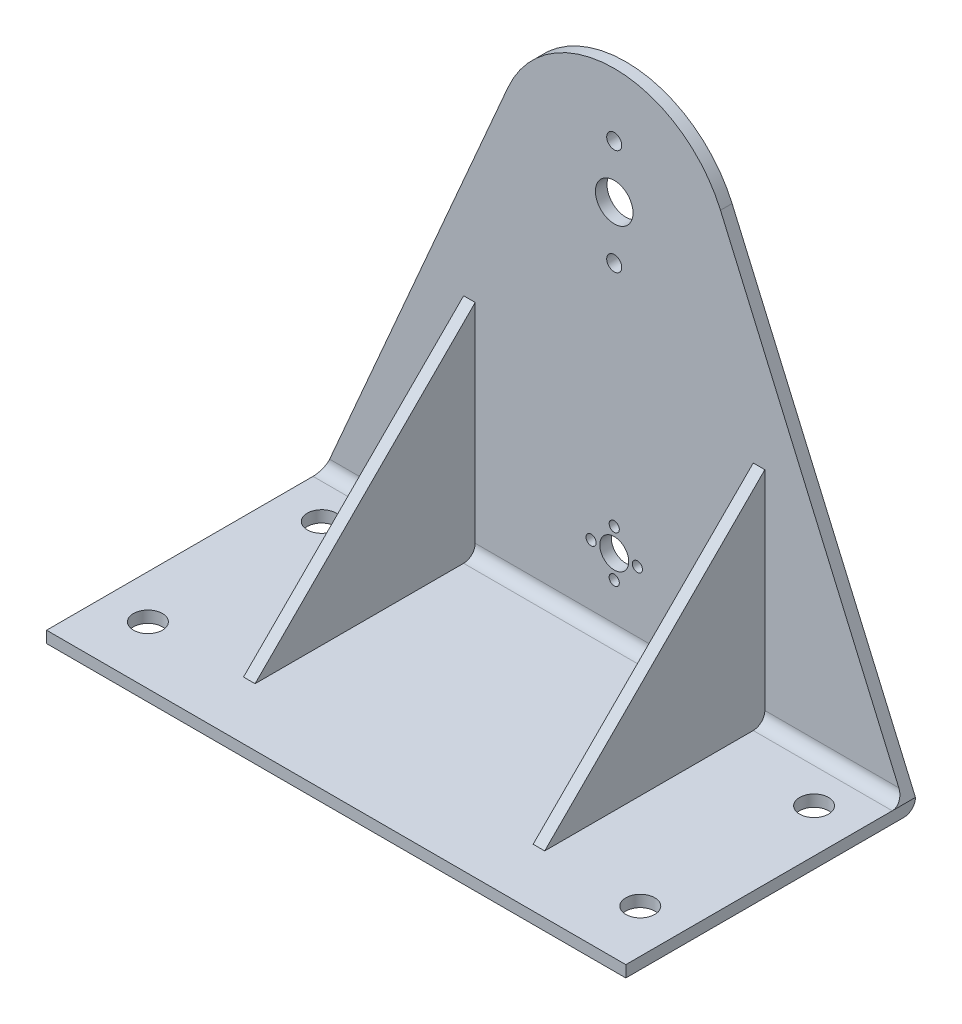
from build123d import *

# Parameters (mm, degrees)
SKETCH1_R           = 6.5
BOSS_EXTRUDE1_DEPTH = 4
SKETCH4_R           = 2.6
CUT_EXTRUDE1_DEPTH  = 10
SKETCH5_W           = 200
SKETCH5_H           = 4
BOSS_EXTRUDE2_DEPTH = 100
FILLET1_R           = 4
SKETCH8_R           = 5
CUT_EXTRUDE2_DEPTH  = 100
SKETCH9_R           = 5
SKETCH9_R_2         = 1.75
CUT_EXTRUDE3_DEPTH  = 10
RIB1_REACH          = 249.79
SKETCH10_WALL_W     = 610.717552724
SKETCH10_WALL_H     = 4


with BuildPart() as part:
    # Sketch1 → Boss-Extrude1 (new body)
    with BuildSketch(Plane.XY):
        with BuildLine():
            Line((100, -4), (100, 0))
            Line((100, 0), (36.695562583, 145.919663525))
            ThreePointArc((36.695562583, 145.919663525), (0, 170), (-36.695562583, 145.919663525))
            Line((-36.695562583, 145.919663525), (-100, 0))
            Line((-100, 0), (-100, -4))
            Line((-100, -4), (100, -4))
        make_face()
        with Locations((0, 130)):
            Circle(SKETCH1_R, mode=Mode.SUBTRACT)
    extrude(amount=BOSS_EXTRUDE1_DEPTH)

    # Sketch4 → Cut-Extrude1 (cut)
    with BuildSketch(Plane(origin=(0, 0, 0), x_dir=(-1, 0, 0), z_dir=(0, 0, -1))):
        with Locations((0, 111.75)):
            Circle(SKETCH4_R)
        with Locations((0, 148.25)):
            Circle(SKETCH4_R)
    extrude(amount=-CUT_EXTRUDE1_DEPTH, mode=Mode.SUBTRACT)

    # Sketch5 → Boss-Extrude2 (add)
    with BuildSketch(Plane(origin=(0, 0, 0), x_dir=(-1, 0, 0), z_dir=(0, 0, -1))):
        with Locations((0, -2)):
            Rectangle(SKETCH5_W, SKETCH5_H)
    extrude(amount=-BOSS_EXTRUDE2_DEPTH)

    # Fillet1
    fillet1_edges = [part.edges().sort_by_distance(p)[0] for p in [
        (0, -4, 0),
        (0, 0, 4),
    ]]
    fillet(fillet1_edges, radius=FILLET1_R)

    # Sketch8 → Cut-Extrude2 (cut)
    with BuildSketch(Plane(origin=(0, 0, 0), x_dir=(1, 0, 0), z_dir=(0, 1, 0))):
        with Locations(Location((-85, -80, 0), (0, 0, 270))):
            Circle(SKETCH8_R)
        with Locations(Location((-85, -20, 0), (0, 0, 270))):
            Circle(SKETCH8_R)
        with Locations(Location((85, -80, 0), (0, 0, 270))):
            Circle(SKETCH8_R)
        with Locations(Location((85, -20, 0), (0, 0, 270))):
            Circle(SKETCH8_R)
    extrude(amount=-CUT_EXTRUDE2_DEPTH, mode=Mode.SUBTRACT)

    # Sketch9 → Cut-Extrude3 (cut)
    with BuildSketch(Plane.XY.offset(4)):
        with Locations((0, 25)):
            Circle(SKETCH9_R)
        with Locations((0, 33)):
            Circle(SKETCH9_R_2)
        with Locations((0, 17)):
            Circle(SKETCH9_R_2)
        with Locations((8, 25)):
            Circle(SKETCH9_R_2)
        with Locations((-8, 25)):
            Circle(SKETCH9_R_2)
    extrude(amount=-CUT_EXTRUDE3_DEPTH, mode=Mode.SUBTRACT)

    # Sketch10 wall → Rib1 (add, up to next)
    with BuildSketch(Plane(origin=(-50, 40, 40), x_dir=(0, 0.707106781187, -0.707106781187), z_dir=(0, -0.707106781187, -0.707106781187)), mode=Mode.PRIVATE) as rib1_sk1:
        Rectangle(SKETCH10_WALL_W, SKETCH10_WALL_H)
    rib1_tool1 = extrude(rib1_sk1.sketch, amount=RIB1_REACH, mode=Mode.PRIVATE) - part.part
    rib1 = rib1_tool1.solids().sort_by_distance((-50, 40, 40))[0]
    add(rib1)

    # Mirror1: Rib1 across plane
    add(rib1.mirror(Plane(origin=(0, 0, 0), x_dir=(0, 0, 1), z_dir=(1, 0, 0))))


solid = part.part
